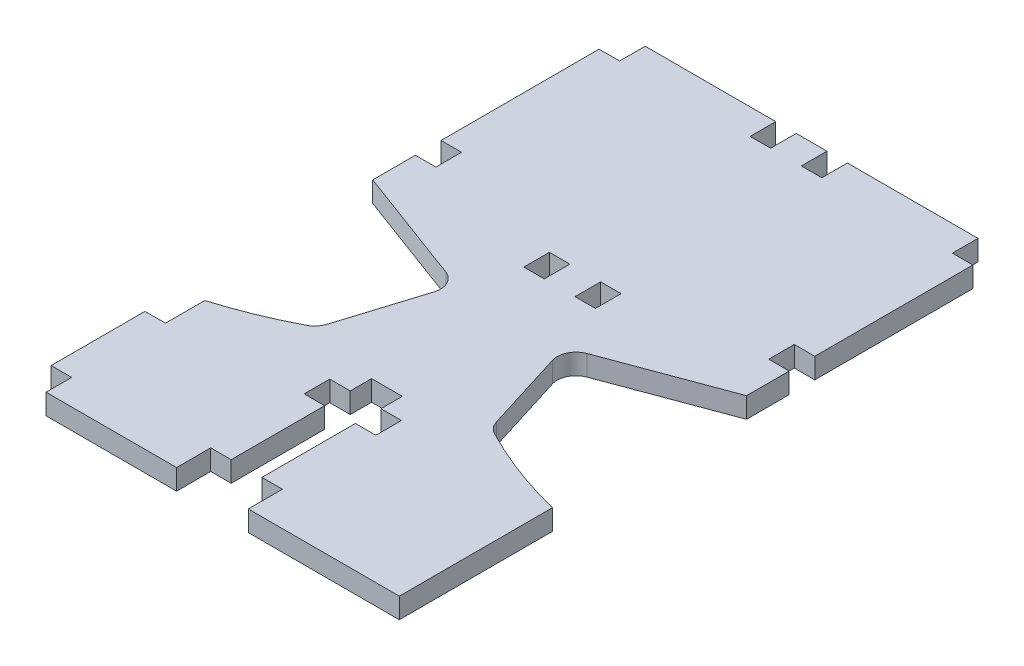
from build123d import *

# Parameters (mm, degrees)
SKETCH1_W           = 6.096
SKETCH1_H           = 7.62
BOSS_EXTRUDE1_DEPTH = 3.048


with BuildPart() as part:
    # Sketch1 → Boss-Extrude1 (new, symmetric)
    with BuildSketch(Plane(origin=(0, 0, 0), x_dir=(1, 0, 0), z_dir=(0, 1, 0))):
        with BuildLine():
            Line((-49.53, 45.72), (-10.668, 45.72))
            Line((-10.668, 45.72), (-10.668, 38.1))
            Line((-10.668, 38.1), (-4.572, 38.1))
            Line((-4.572, 38.1), (-4.572, 45.72))
            Line((-4.572, 45.72), (4.572, 45.72))
            Line((4.572, 45.72), (4.572, 38.1))
            Line((4.572, 38.1), (10.668, 38.1))
            Line((10.668, 38.1), (10.668, 45.72))
            Line((10.668, 45.72), (49.53, 45.72))
            Line((49.53, 45.72), (49.53, 38.1))
            Line((49.53, 38.1), (55.626, 38.1))
            Line((55.626, 38.1), (55.626, -8.951856626))
            Line((55.626, -8.951856626), (49.53, -8.951856626))
            Line((49.53, -8.951856626), (49.53, -16.571856626))
            Line((49.53, -16.571856626), (55.626, -16.571856626))
            Line((55.626, -16.571856626), (55.626, -29.271856626))
            Line((55.626, -29.271856626), (21.019827136, -42.136821893))
            ThreePointArc((21.019827136, -42.136821893), (17.95098831, -44.911778638), (17.631953735, -49.036869377))
            Line((17.631953735, -49.036869377), (25.187729856, -73.287029113))
            ThreePointArc((25.187729856, -73.287029113), (26.234780075, -75.207903536), (27.939063878, -76.579577488))
            ThreePointArc((27.939063878, -76.579577488), (41.468907088, -82.632484358), (55.626, -87.022365809))
            Line((55.626, -87.022365809), (55.626, -132.617292876))
            Line((55.626, -132.617292876), (10.668, -132.617292876))
            Line((10.668, -132.617292876), (10.668, -122.457292876))
            Line((10.668, -122.457292876), (4.572, -122.457292876))
            Line((4.572, -122.457292876), (4.572, -94.642365809))
            Line((4.572, -94.642365809), (10.668, -94.642365809))
            Line((10.668, -94.642365809), (10.668, -87.022365809))
            Line((10.668, -87.022365809), (4.572, -87.022365809))
            Line((4.572, -87.022365809), (4.572, -80.672365809))
            Line((4.572, -80.672365809), (-4.572, -80.672365809))
            Line((-4.572, -80.672365809), (-4.572, -87.022365809))
            Line((-4.572, -87.022365809), (-10.668, -87.022365809))
            Line((-10.668, -87.022365809), (-10.668, -94.642365809))
            Line((-10.668, -94.642365809), (-4.572, -94.642365809))
            Line((-4.572, -94.642365809), (-4.572, -122.457292876))
            Line((-4.572, -122.457292876), (-10.668, -122.457292876))
            Line((-10.668, -122.457292876), (-10.668, -132.617292876))
            Line((-10.668, -132.617292876), (-49.53, -132.617292876))
            Line((-49.53, -132.617292876), (-49.53, -124.997292876))
            Line((-49.53, -124.997292876), (-55.626, -124.997292876))
            Line((-55.626, -124.997292876), (-55.626, -97.057292876))
            Line((-55.626, -97.057292876), (-49.53, -97.057292876))
            Line((-49.53, -97.057292876), (-49.53, -85.359826344))
            ThreePointArc((-49.53, -85.359826344), (-38.527111219, -81.479756652), (-27.939063878, -76.579577488))
            ThreePointArc((-27.939063878, -76.579577488), (-26.234780075, -75.207903536), (-25.187729856, -73.287029113))
            Line((-25.187729856, -73.287029113), (-17.631953735, -49.036869377))
            ThreePointArc((-17.631953735, -49.036869377), (-17.95098831, -44.911778638), (-21.019827136, -42.136821893))
            Line((-21.019827136, -42.136821893), (-55.626, -29.271856626))
            Line((-55.626, -29.271856626), (-55.626, -16.571856626))
            Line((-55.626, -16.571856626), (-49.53, -16.571856626))
            Line((-49.53, -16.571856626), (-49.53, -8.951856626))
            Line((-49.53, -8.951856626), (-55.626, -8.951856626))
            Line((-55.626, -8.951856626), (-55.626, 38.1))
            Line((-55.626, 38.1), (-49.53, 38.1))
            Line((-49.53, 38.1), (-49.53, 45.72))
        make_face()
        with Locations((7.62, -25.461856626)):
            Rectangle(SKETCH1_W, SKETCH1_H, mode=Mode.SUBTRACT)
        with Locations((-7.62, -25.461856626)):
            Rectangle(SKETCH1_W, SKETCH1_H, mode=Mode.SUBTRACT)
    extrude(amount=BOSS_EXTRUDE1_DEPTH, both=True)


solid = part.part
